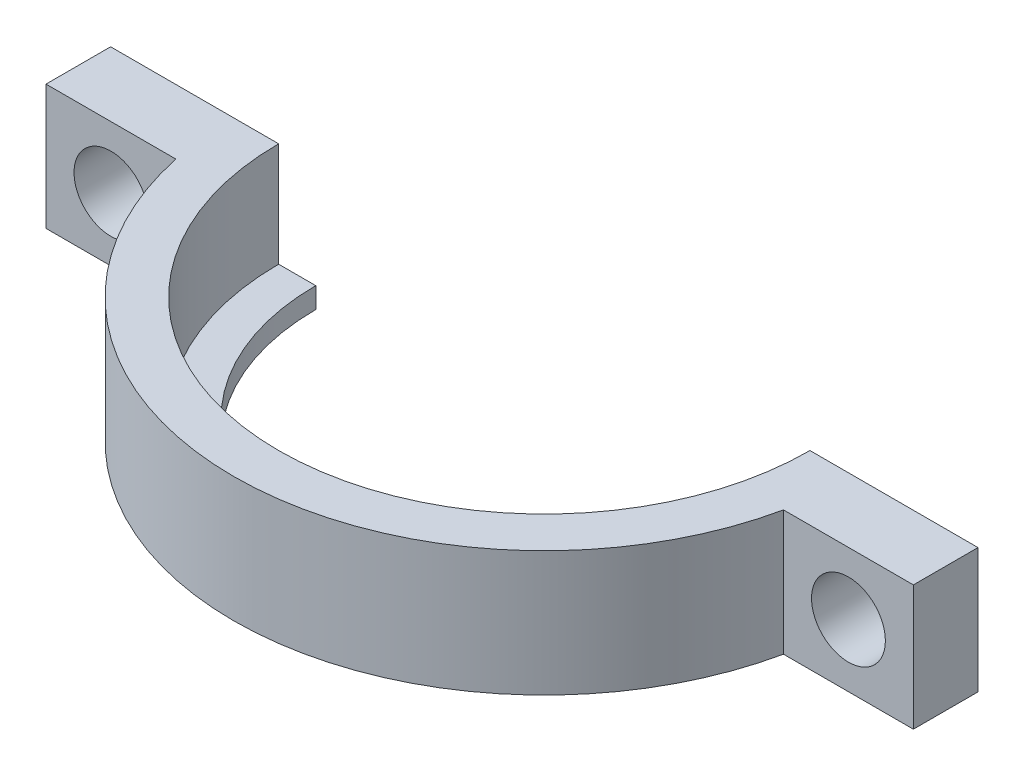
from build123d import *

# Parameters (mm, degrees)
BOSS_EXTRUDE1_DEPTH     = 5
BOSS_EXTRUDE2_DEPTH     = 3
BOSS_EXTRUDE3_DEPTH     = 3
SKETCH10_W              = 9.5
SKETCH10_H              = 5
BOSS_EXTRUDE4_DEPTH     = 15.78
SKETCH11_W              = 9.5
SKETCH11_H              = 2
BOSS_EXTRUDE5_DEPTH     = 40
BOSS_EXTRUDE6_DEPTH     = 6.09393
SKETCH14_R              = 1.8
CUT_EXTRUDE1_DEPTH      = 6.3
SKETCH15_W              = 51.153217575
SKETCH15_H              = 86.05062267
CUT_EXTRUDE3_DEPTH      = 6
CUT_EXTRUDE3_DEPTH_BACK = 19.78
SKETCH16_W              = 9.603970124
SKETCH16_H              = 11.884913028
CUT_EXTRUDE4_DEPTH      = 17.733728816


with BuildPart() as part:
    # Sketch3 → Revolve1 (revolve)
    with BuildSketch(Plane.XY):
        Polygon((-62.694264441, 10.250679103), (-62.694264441, 11.733728816), (-64.884531744, 11.733728816), (-64.884531744, 5.639799249), (-60.884531744, 5.639799249), (-60.884531744, 6.650679103), (-62.694264441, 6.650679103), align=None)
    revolve(axis=Axis((-49.744264441, 0, 0), (0, 1, 0)))

    # Sketch7 → Boss-Extrude1 (add)
    with BuildSketch(Plane(origin=(0, 11.733728816, 0), x_dir=(1, 0, 0), z_dir=(0, 1, 0))):
        with BuildLine():
            Line((-50.244264441, 15.132008921), (-50.244264441, 12.94034389))
            ThreePointArc((-50.244264441, 12.94034389), (-49.744264441, 12.95), (-49.244264441, 12.94034389))
            Line((-49.244264441, 12.94034389), (-49.244264441, 15.132008921))
            ThreePointArc((-49.244264441, 15.132008921), (-49.744264441, 15.140267302), (-50.244264441, 15.132008921))
        make_face()
    extrude(amount=BOSS_EXTRUDE1_DEPTH)

    # Sketch8 → Boss-Extrude2 (add)
    with BuildSketch(Plane(origin=(0, 16.733728816, 0), x_dir=(1, 0, 0), z_dir=(0, 1, 0))):
        with BuildLine():
            Line((-50.244264441, 15.132008921), (-50.244264441, 12.94034389))
            Line((-50.244264441, 12.94034389), (-50.244264441, -4.55965611))
            Line((-50.244264441, -4.55965611), (-49.244264441, -4.55965611))
            Line((-49.244264441, -4.55965611), (-49.244264441, 12.94034389))
            Line((-49.244264441, 12.94034389), (-49.244264441, 15.132008921))
            ThreePointArc((-49.244264441, 15.132008921), (-49.744264441, 15.140267302), (-50.244264441, 15.132008921))
        make_face()
    extrude(amount=-BOSS_EXTRUDE2_DEPTH)

    # Sketch9 → Boss-Extrude3 (add)
    with BuildSketch(Plane(origin=(0, 11.733728816, 0), x_dir=(1, 0, 0), z_dir=(0, 1, 0))):
        with BuildLine():
            Line((-54.494264441, 14.375854548), (-54.494264441, 39.375854548))
            Line((-54.494264441, 39.375854548), (-44.994264441, 39.375854548))
            Line((-44.994264441, 39.375854548), (-44.994264441, 14.375854548))
            ThreePointArc((-44.994264441, 14.375854548), (-47.092177082, 14.906177465), (-49.244264441, 15.132008921))
            ThreePointArc((-49.244264441, 15.132008921), (-49.744264441, 15.140267302), (-50.244264441, 15.132008921))
            ThreePointArc((-50.244264441, 15.132008921), (-52.3963518, 14.906177465), (-54.494264441, 14.375854548))
        make_face()
    extrude(amount=-BOSS_EXTRUDE3_DEPTH)

    # Sketch10 → Boss-Extrude4 (add)
    with BuildSketch(Plane.XZ.offset(-8.733728816)):
        with Locations((-49.744264441, -36.875854548)):
            Rectangle(SKETCH10_W, SKETCH10_H)
    extrude(amount=BOSS_EXTRUDE4_DEPTH)

    # Sketch11 → Boss-Extrude5 (add)
    with BuildSketch(Plane(origin=(0, 0, -39.375854548), x_dir=(-1, 0, 0), z_dir=(0, 0, -1))):
        with Locations((49.744264441, -6.046271184)):
            Rectangle(SKETCH11_W, SKETCH11_H)
    extrude(amount=BOSS_EXTRUDE5_DEPTH)

    # Sketch13 → Boss-Extrude6 (add)
    with BuildSketch(Plane(origin=(0, 11.733728816, 0), x_dir=(1, 0, 0), z_dir=(0, 1, 0))):
        with BuildLine():
            Line((-28.603997139, 3.15), (-34.935307895, 3.15))
            ThreePointArc((-34.935307895, 3.15), (-34.603997139, 0), (-34.935307895, -3.15))
            Line((-34.935307895, -3.15), (-28.603997139, -3.15))
            Line((-28.603997139, -3.15), (-28.603997139, 3.15))
        make_face()
        with BuildLine():
            Line((-70.884531744, 3.15), (-70.884531744, -3.15))
            Line((-70.884531744, -3.15), (-64.553220987, -3.15))
            ThreePointArc((-64.553220987, -3.15), (-64.884531744, 0), (-64.553220987, 3.15))
            Line((-64.553220987, 3.15), (-70.884531744, 3.15))
        make_face()
    extrude(amount=-BOSS_EXTRUDE6_DEPTH)

    # Sketch14 → Cut-Extrude1 (cut)
    with BuildSketch(Plane.XY.offset(3.15)):
        with Locations((-31.769652517, 8.686764033)):
            Circle(SKETCH14_R)
        with Locations((-67.718876365, 8.686764033)):
            Circle(SKETCH14_R)
    extrude(amount=-CUT_EXTRUDE1_DEPTH, mode=Mode.SUBTRACT)

    # Sketch15 → Cut-Extrude3 (cut, two sides)
    with BuildSketch(Plane(origin=(0, 11.733728816, 0), x_dir=(1, 0, 0), z_dir=(0, 1, 0))) as cut_extrude3_sk:
        with Locations((-49.018725857, 43.025311335)):
            Rectangle(SKETCH15_W, SKETCH15_H)
    extrude(amount=CUT_EXTRUDE3_DEPTH, mode=Mode.SUBTRACT)
    extrude(cut_extrude3_sk.sketch, amount=-CUT_EXTRUDE3_DEPTH_BACK, mode=Mode.SUBTRACT)

    # Sketch16 → Cut-Extrude4 (cut, through all)
    with BuildSketch(Plane(origin=(0, 0, 0), x_dir=(1, 0, 0), z_dir=(0, 1, 0))):
        with Locations((-50.086315959, -0.525030424)):
            Rectangle(SKETCH16_W, SKETCH16_H)
    extrude(amount=CUT_EXTRUDE4_DEPTH, mode=Mode.SUBTRACT)


solid = part.part
